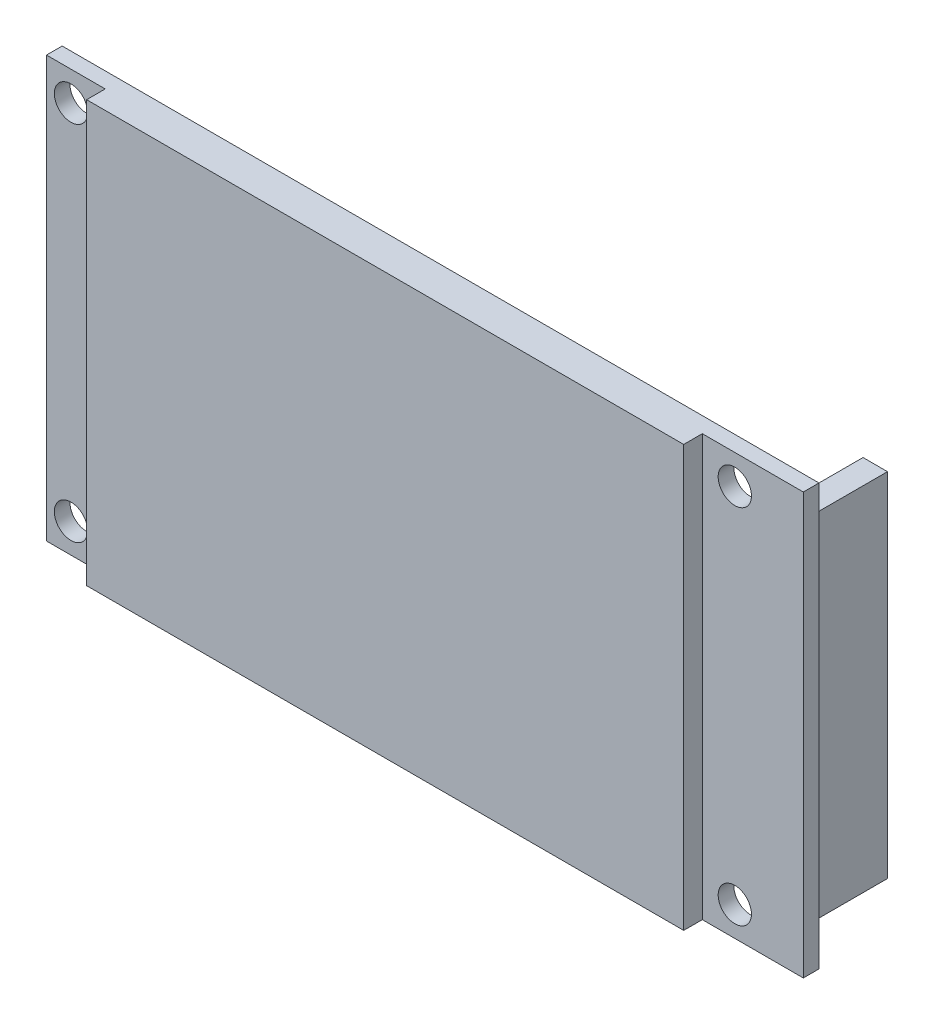
from build123d import *

# Parameters (mm, degrees)
SKETCH1_W           = 77.32
SKETCH1_H           = 43
SKETCH1_R           = 1.7
BOSS_EXTRUDE1_DEPTH = 1.6
SKETCH3_W           = 61
SKETCH3_H           = 43
BOSS_EXTRUDE3_DEPTH = 3.5
SKETCH4_W           = 2.5
SKETCH4_H           = 36
SKETCH4_H_2         = 11
BOSS_EXTRUDE4_DEPTH = 8


with BuildPart() as part:
    # Sketch1 → Boss-Extrude1 (new body)
    with BuildSketch(Plane.XY):
        with Locations((38.66, 21.5)):
            Rectangle(SKETCH1_W, SKETCH1_H)
        with Locations((70.32, 40)):
            Circle(SKETCH1_R, mode=Mode.SUBTRACT)
        with Locations((70.32, 3)):
            Circle(SKETCH1_R, mode=Mode.SUBTRACT)
        with Locations((2.5, 3)):
            Circle(SKETCH1_R, mode=Mode.SUBTRACT)
        with Locations((2.5, 40)):
            Circle(SKETCH1_R, mode=Mode.SUBTRACT)
    extrude(amount=BOSS_EXTRUDE1_DEPTH)

    # Sketch3 → Boss-Extrude3 (add)
    with BuildSketch(Plane(origin=(0, 0, 0), x_dir=(-1, 0, 0), z_dir=(0, 0, -1))):
        with Locations((-36.5, 21.5)):
            Rectangle(SKETCH3_W, SKETCH3_H)
    extrude(amount=-BOSS_EXTRUDE3_DEPTH)

    # Sketch4 → Boss-Extrude4 (add)
    with BuildSketch(Plane(origin=(0, 0, 0), x_dir=(-1, 0, 0), z_dir=(0, 0, -1))):
        with Locations((-75.07, 21.5)):
            Rectangle(SKETCH4_W, SKETCH4_H)
        with Locations((-2.25, 21.5)):
            Rectangle(SKETCH4_W, SKETCH4_H_2)
    extrude(amount=BOSS_EXTRUDE4_DEPTH)


solid = part.part
